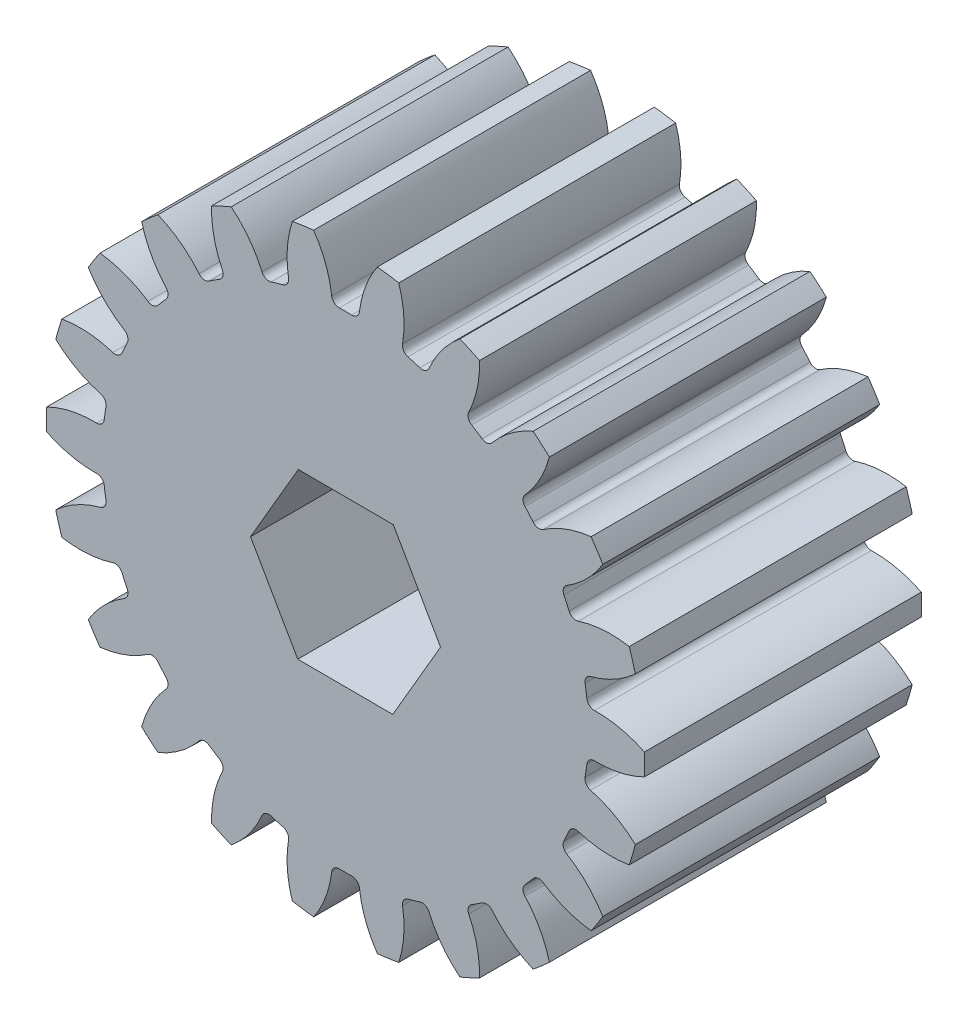
from build123d import *

# Parameters (mm, degrees)
SKETCH1_R                = 24
BOSS_EXTRUDE1_DEPTH      = 19.05
BOSS_EXTRUDE1_DEPTH_BACK = 3.175
CUT_EXTRUDE2_DEPTH       = 23.225
FILLET2_R                = 0.6
CIRPATTERN2_COUNT        = 22
FILLET2_OF_CIRPATTERN2_R = 0.6
CUT_EXTRUDE3_DEPTH       = 23.2250001


with BuildPart() as part:
    # Sketch1 → Boss-Extrude1 (new body, two sides)
    with BuildSketch(Plane.XY) as boss_extrude1_sk:
        Circle(SKETCH1_R)
    extrude(amount=BOSS_EXTRUDE1_DEPTH)
    extrude(boss_extrude1_sk.sketch, amount=-BOSS_EXTRUDE1_DEPTH_BACK)

    # Sketch3 → Cut-Extrude2 (cut, through all)
    with BuildSketch(Plane(origin=(0, 0, -3.175), x_dir=(-1, 0, 0), z_dir=(0, 0, -1))):
        with BuildLine():
            ThreePointArc((-3.283383383, 24.783449993), (-1.715772066, 22.318455925), (-1.06349074, 19.470978081))
            ThreePointArc((-1.06349074, 19.470978081), (0, 19.5), (1.06349074, 19.470978081))
            ThreePointArc((1.06349074, 19.470978081), (1.715772066, 22.318455925), (3.283383383, 24.783449993))
            ThreePointArc((3.283383383, 24.783449993), (0, 25), (-3.283383383, 24.783449993))
        make_face()
    cut_extrude2 = extrude(amount=-CUT_EXTRUDE2_DEPTH, mode=Mode.SUBTRACT)

    # Fillet2
    fillet2_edges = [part.edges().sort_by_distance(p)[0] for p in [
        (-1.06349074, 19.470978081, 7.9375),
        (1.06349074, 19.470978081, 7.9375),
    ]]
    fillet(fillet2_edges, radius=FILLET2_R)

    # CirPattern2: Cut-Extrude2 ×22 about axis
    cirpattern2_axis = Axis((0, 0, 0), (0, 0, 1))
    for i in range(1, CIRPATTERN2_COUNT):
        add(cut_extrude2.rotate(cirpattern2_axis, i * 360 / CIRPATTERN2_COUNT), mode=Mode.SUBTRACT)

    # Fillet2 of CirPattern2
    fillet2_of_cirpattern2_edges = [part.edges().sort_by_distance(p)[0] for p in [
        (-6.506020331, 18.382646693, 7.9375),
        (-4.465196547, 18.981886624, 7.9375),
        (-11.421470848, 15.805062596, 7.9375),
        (-9.632140165, 16.954995602, 7.9375),
        (-15.411621724, 11.947046323, 7.9375),
        (-14.018745071, 13.554511671, 7.9375),
        (-18.153214663, 7.121151409, 7.9375),
        (-17.269634624, 9.055921816, 7.9375),
        (-19.424142112, 1.718343159, 7.9375),
        (-19.121441087, 3.823675034, 7.9375),
        (-19.121441087, -3.823675034, 7.9375),
        (-19.424142112, -1.718343159, 7.9375),
        (-17.269634624, -9.055921816, 7.9375),
        (-18.153214663, -7.121151409, 7.9375),
        (-14.018745071, -13.554511671, 7.9375),
        (-15.411621724, -11.947046323, 7.9375),
        (-9.632140165, -16.954995602, 7.9375),
        (-11.421470848, -15.805062596, 7.9375),
        (-4.465196547, -18.981886624, 7.9375),
        (-6.506020331, -18.382646693, 7.9375),
        (1.06349074, -19.470978081, 7.9375),
        (-1.06349074, -19.470978081, 7.9375),
        (6.506020331, -18.382646693, 7.9375),
        (4.465196547, -18.981886624, 7.9375),
        (11.421470848, -15.805062596, 7.9375),
        (9.632140165, -16.954995602, 7.9375),
        (15.411621724, -11.947046323, 7.9375),
        (14.018745071, -13.554511671, 7.9375),
        (18.153214663, -7.121151409, 7.9375),
        (17.269634624, -9.055921816, 7.9375),
        (19.424142112, -1.718343159, 7.9375),
        (19.121441087, -3.823675034, 7.9375),
        (19.121441087, 3.823675034, 7.9375),
        (19.424142112, 1.718343159, 7.9375),
        (17.269634624, 9.055921816, 7.9375),
        (18.153214663, 7.121151409, 7.9375),
        (14.018745071, 13.554511671, 7.9375),
        (15.411621724, 11.947046323, 7.9375),
        (9.632140165, 16.954995602, 7.9375),
        (11.421470848, 15.805062596, 7.9375),
        (4.465196547, 18.981886624, 7.9375),
        (6.506020331, 18.382646693, 7.9375),
    ]]
    fillet(fillet2_of_cirpattern2_edges, radius=FILLET2_OF_CIRPATTERN2_R)

    # Sketch4 → Cut-Extrude3 (cut, through all)
    with BuildSketch(Plane.XY.offset(19.05)):
        Polygon((3.836203431, 6.590444945), (-3.789391029, 6.617472098), (-7.62559446, 0.027027153), (-3.836203431, -6.590444945), (3.789391029, -6.617472098), (7.62559446, -0.027027153), align=None)
    extrude(amount=-CUT_EXTRUDE3_DEPTH, mode=Mode.SUBTRACT)


solid = part.part
